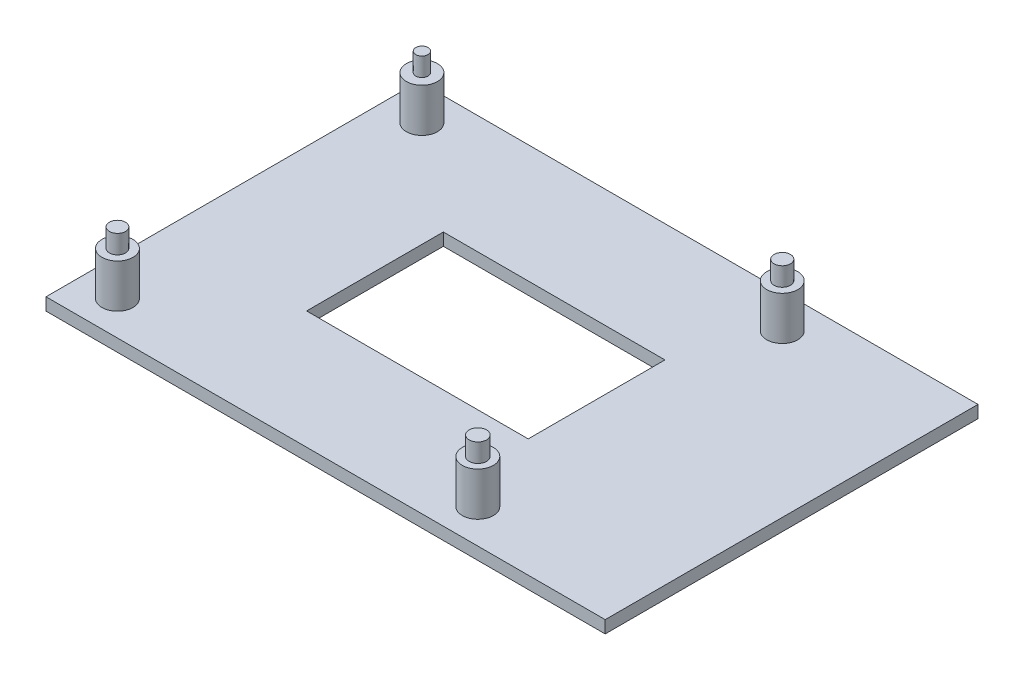
from build123d import *

# Parameters (mm, degrees)
CROQUIS1_W              = 90
CROQUIS1_H              = 60
SALIENTE_EXTRUIR1_DEPTH = 2
CROQUIS2_R              = 2.5
SALIENTE_EXTRUIR2_DEPTH = 7
CROQUIS3_R              = 0.98725552
CROQUIS3_R_2            = 1.31678764
CROQUIS3_R_3            = 1.399541148
CROQUIS3_R_4            = 1.294656753
SALIENTE_EXTRUIR3_DEPTH = 3
CROQUIS4_W              = 35.666485166
CROQUIS4_H              = 22.011405482
CORTAR_EXTRUIR1_DEPTH   = 3


with BuildPart() as part:
    # Croquis1 → Saliente-Extruir1 (new body)
    with BuildSketch(Plane(origin=(0, 0, 0), x_dir=(1, 0, 0), z_dir=(0, 1, 0))):
        Rectangle(CROQUIS1_W, CROQUIS1_H)
    extrude(amount=SALIENTE_EXTRUIR1_DEPTH)

    # Croquis2 → Saliente-Extruir2 (add)
    with BuildSketch(Plane(origin=(0, 2, 0), x_dir=(1, 0, 0), z_dir=(0, 1, 0))):
        with Locations((-39, 24.5)):
            Circle(CROQUIS2_R)
        with Locations((19, 24.5)):
            Circle(CROQUIS2_R)
        with Locations((19, -24.5)):
            Circle(CROQUIS2_R)
        with Locations((-39, -24.5)):
            Circle(CROQUIS2_R)
    extrude(amount=SALIENTE_EXTRUIR2_DEPTH)

    # Croquis3 → Saliente-Extruir3 (add)
    with BuildSketch(Plane(origin=(0, 9, 0), x_dir=(1, 0, 0), z_dir=(0, 1, 0))):
        with Locations((-39, 24.5)):
            Circle(CROQUIS3_R)
        with Locations((19, 24.5)):
            Circle(CROQUIS3_R_2)
        with Locations((19, -24.5)):
            Circle(CROQUIS3_R_3)
        with Locations((-39, -24.5)):
            Circle(CROQUIS3_R_4)
    extrude(amount=SALIENTE_EXTRUIR3_DEPTH)

    # Croquis4 → Cortar-Extruir1 (cut)
    with BuildSketch(Plane(origin=(0, 2, 0), x_dir=(1, 0, 0), z_dir=(0, 1, 0))):
        with Locations((-4.220482568, 0)):
            Rectangle(CROQUIS4_W, CROQUIS4_H)
    extrude(amount=-CORTAR_EXTRUIR1_DEPTH, mode=Mode.SUBTRACT)


solid = part.part
